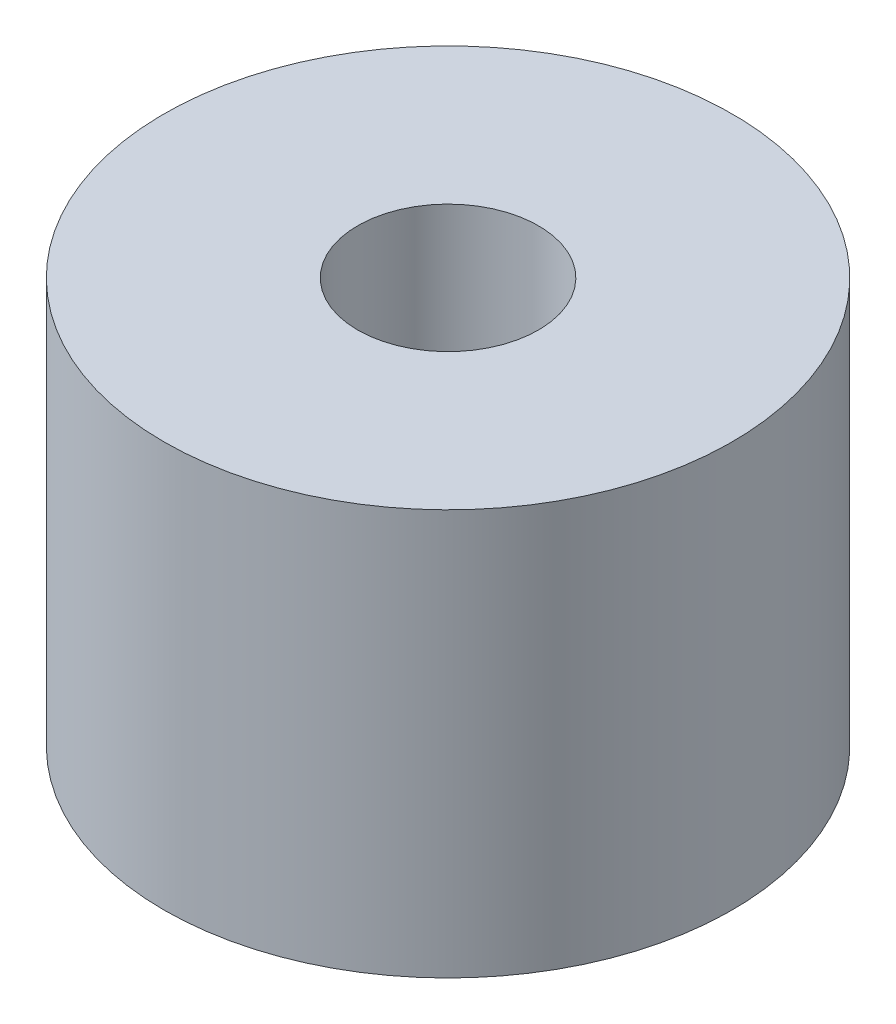
from build123d import *

# Parameters (mm, degrees)
SKETCH1_R           = 11
SKETCH1_R_2         = 3.5
BOSS_EXTRUDE1_DEPTH = 15.7


with BuildPart() as part:
    # Sketch1 → Boss-Extrude1 (new body)
    with BuildSketch(Plane(origin=(0, 0, 0), x_dir=(1, 0, 0), z_dir=(0, 1, 0))):
        Circle(SKETCH1_R)
        Circle(SKETCH1_R_2, mode=Mode.SUBTRACT)
    extrude(amount=BOSS_EXTRUDE1_DEPTH)


solid = part.part
